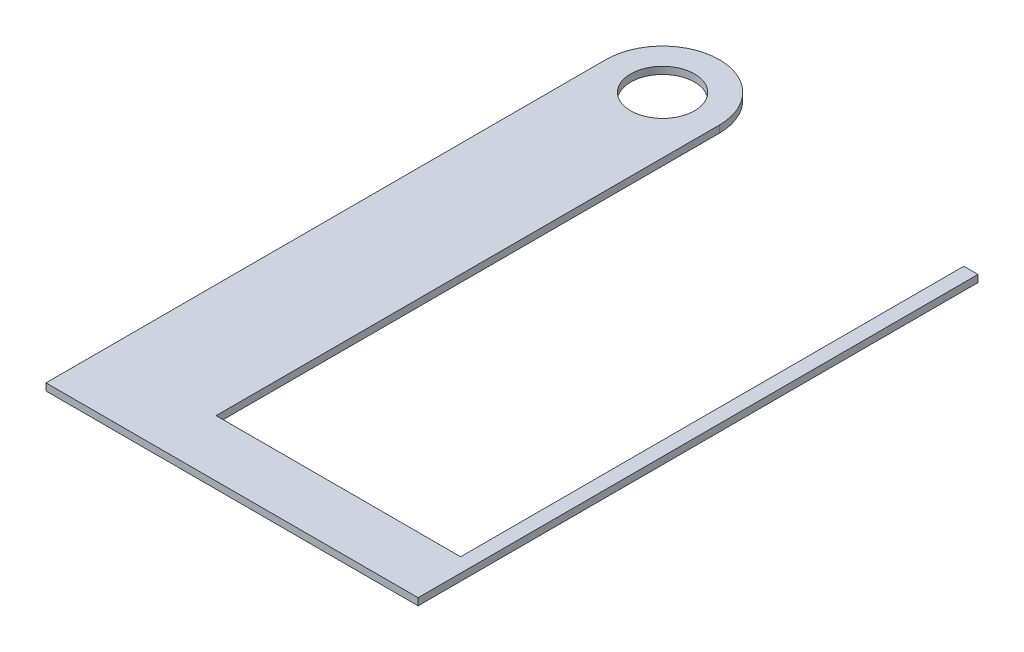
from build123d import *

# Parameters (mm, degrees)
SKETCH1_R           = 14.3129
BOSS_EXTRUDE1_DEPTH = 3.175


with BuildPart() as part:
    # Sketch1 → Boss-Extrude1 (new body)
    with BuildSketch(Plane(origin=(0, 0, 0), x_dir=(1, 0, 0), z_dir=(0, 1, 0))):
        with BuildLine():
            Line((-25.4, 0), (-25.4, -250.825))
            Line((-25.4, -250.825), (141.2875, -250.825))
            Line((141.2875, -250.825), (141.2875, 0))
            Line((141.2875, 0), (134.9375, 0))
            Line((134.9375, 0), (134.9375, -225.425))
            Line((134.9375, -225.425), (25.4, -225.425))
            Line((25.4, -225.425), (25.4, 0))
            ThreePointArc((25.4, 0), (0, 25.4), (-25.4, 0))
        make_face()
        Circle(SKETCH1_R, mode=Mode.SUBTRACT)
    extrude(amount=BOSS_EXTRUDE1_DEPTH)


solid = part.part
